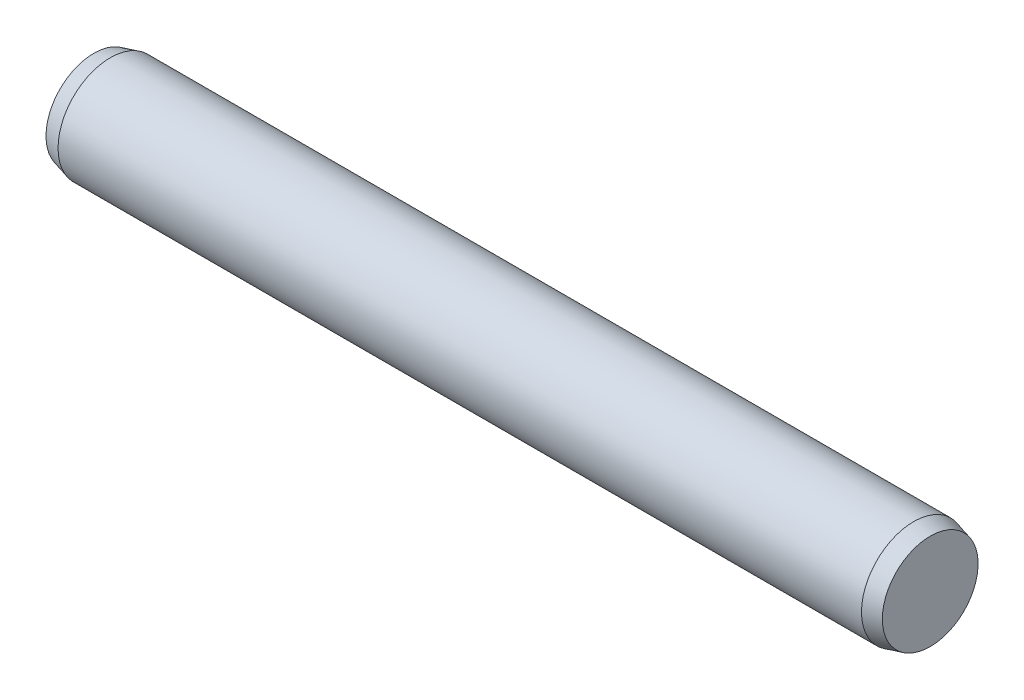
from build123d import *


with BuildPart() as part:
    # Sketch1 → Base-Revolve (revolve)
    with BuildSketch(Plane.XY):
        Polygon((0, 0), (32, 0), (32, 1.831192009), (31.37, 2), (0.63, 2), (0, 1.831192009), align=None)
    revolve(axis=Axis((-6.35, 0, 0), (1, 0, 0)))


solid = part.part
